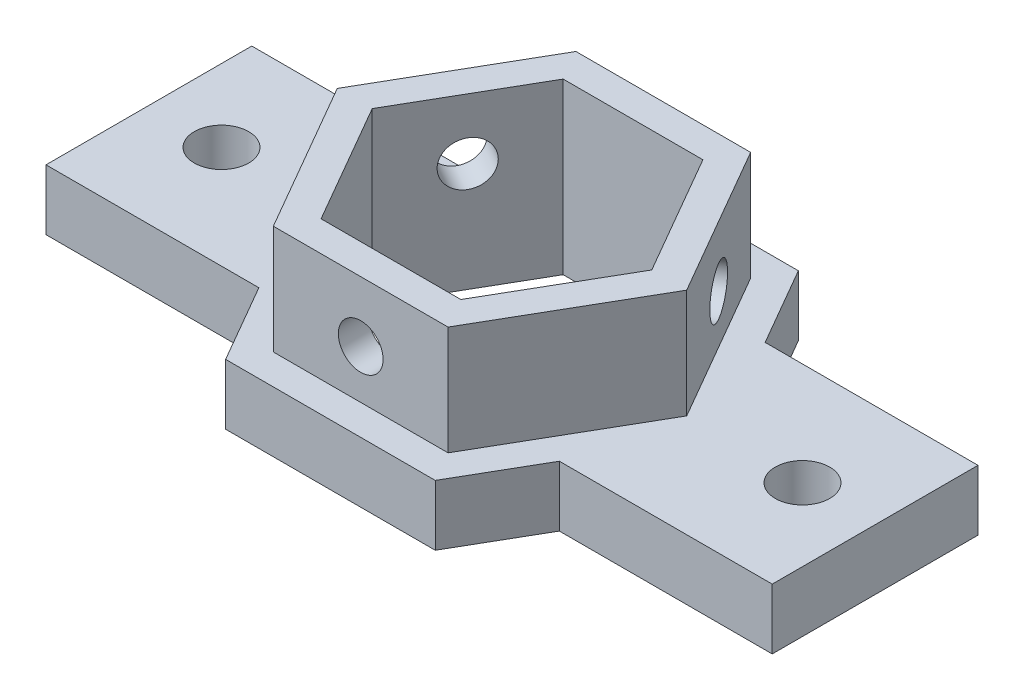
from build123d import *

# Parameters (mm, degrees)
BOSS_EXTRUDE1_DEPTH = 5
BOSS_EXTRUDE2_DEPTH = 9
SKETCH4_R           = 2.25
CUT_EXTRUDE1_DEPTH  = 6
SKETCH5_R           = 1.85
CUT_EXTRUDE2_DEPTH  = 5
SKETCH6_R           = 2
CUT_EXTRUDE3_DEPTH  = 5
SKETCH7_R           = 1.85
CUT_EXTRUDE4_DEPTH  = 5


with BuildPart() as part:
    # Sketch1 → Boss-Extrude1 (new body)
    with BuildSketch(Plane(origin=(0, 0, 0), x_dir=(1, 0, 0), z_dir=(0, 1, 0))):
        Polygon((-30, -8.5), (-12.413030788, -8.5), (-8.660254038, -15), (8.660254038, -15), (12.413030788, -8.5), (30, -8.5), (30, 8.5), (12.413030788, 8.5), (8.660254038, 15), (-8.660254038, 15), (-12.413030788, 8.5), (-30, 8.5), align=None)
        Polygon((-5.773502692, -10), (-11.547005384, 0), (-5.773502692, 10), (5.773502692, 10), (11.547005384, 0), (5.773502692, -10), align=None, mode=Mode.SUBTRACT)
    extrude(amount=BOSS_EXTRUDE1_DEPTH)

    # Sketch3 → Boss-Extrude2 (add)
    with BuildSketch(Plane(origin=(0, 5, 0), x_dir=(1, 0, 0), z_dir=(0, 1, 0))):
        Polygon((-14.43375673, 0), (-7.216878365, -12.5), (7.216878365, -12.5), (14.43375673, 0), (7.216878365, 12.5), (-7.216878365, 12.5), align=None)
        Polygon((-11.547005384, 0), (-5.773502692, -10), (5.773502692, -10), (11.547005384, 0), (5.773502692, 10), (-5.773502692, 10), align=None, mode=Mode.SUBTRACT)
    extrude(amount=BOSS_EXTRUDE2_DEPTH)

    # Sketch4 → Cut-Extrude1 (cut, through all)
    with BuildSketch(Plane(origin=(0, 5, 0), x_dir=(1, 0, 0), z_dir=(0, 1, 0))):
        with Locations(Location((-24, 0, 0), (0, 0, 270))):  # turned: the seam where the file's is
            Circle(SKETCH4_R)
    cut_extrude1 = extrude(amount=-CUT_EXTRUDE1_DEPTH, mode=Mode.SUBTRACT)

    # Mirror1: Cut-Extrude1 across plane
    add(cut_extrude1.mirror(Plane(origin=(0, 0, 0), x_dir=(0, 0, 1), z_dir=(1, 0, 0))), mode=Mode.SUBTRACT)

    # Sketch5 → Cut-Extrude2 (cut)
    with BuildSketch(Plane.XY.offset(15)):
        with Locations(Location((0, 9, 0), (0, 0, 180))):  # turned: the seam where the file's is
            Circle(SKETCH5_R)
    extrude(amount=-CUT_EXTRUDE2_DEPTH, mode=Mode.SUBTRACT)

    # Sketch6 → Cut-Extrude3 (cut)
    with BuildSketch(Plane(origin=(12.990381057, 0, -7.5), x_dir=(-0.5, 0, -0.866025404), z_dir=(0.866025404, 0, -0.5))):
        with Locations(Location((0, 9, 0), (0, 0, 180))):  # turned: the seam where the file's is
            Circle(SKETCH6_R)
    extrude(amount=-CUT_EXTRUDE3_DEPTH, mode=Mode.SUBTRACT)

    # Sketch7 → Cut-Extrude4 (cut)
    with BuildSketch(Plane(origin=(-12.990381057, 0, -7.5), x_dir=(-0.5, 0, 0.866025404), z_dir=(-0.866025404, 0, -0.5))):
        with Locations(Location((0, 9, 0), (0, 0, 180))):  # turned: the seam where the file's is
            Circle(SKETCH7_R)
    extrude(amount=-CUT_EXTRUDE4_DEPTH, mode=Mode.SUBTRACT)


solid = part.part
